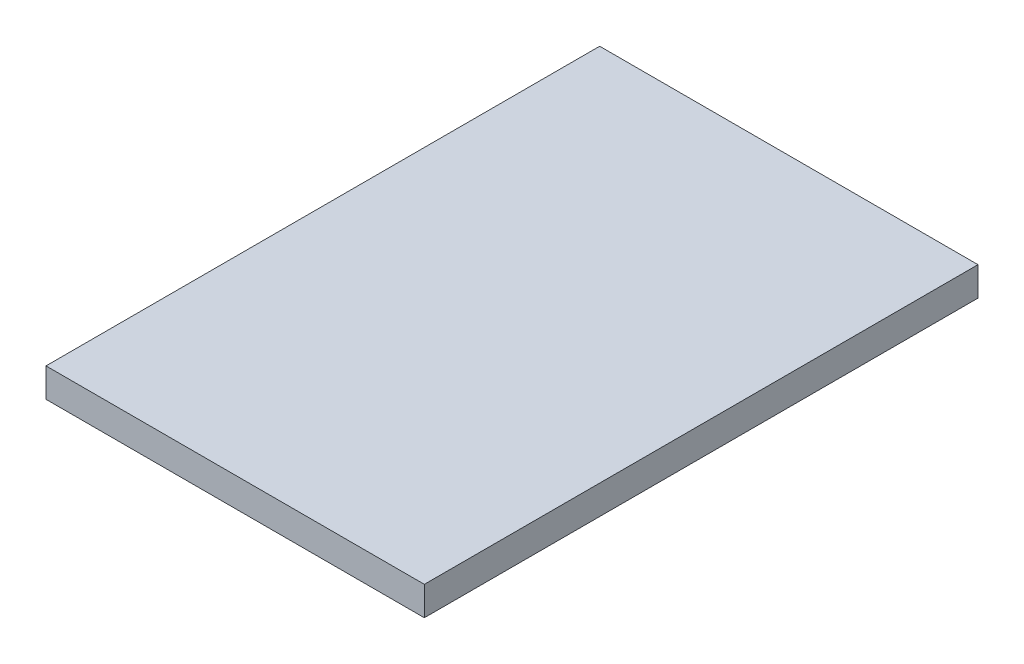
from build123d import *

# Parameters (mm, degrees)
SKETCH1_W           = 20.5
SKETCH1_H           = 30
BOSS_EXTRUDE1_DEPTH = 1.57


with BuildPart() as part:
    # Sketch1 → Boss-Extrude1 (new body)
    with BuildSketch(Plane(origin=(0, 0, 0), x_dir=(1, 0, 0), z_dir=(0, 1, 0))):
        with Locations((10.25, 15)):
            Rectangle(SKETCH1_W, SKETCH1_H)
    extrude(amount=BOSS_EXTRUDE1_DEPTH)


solid = part.part
